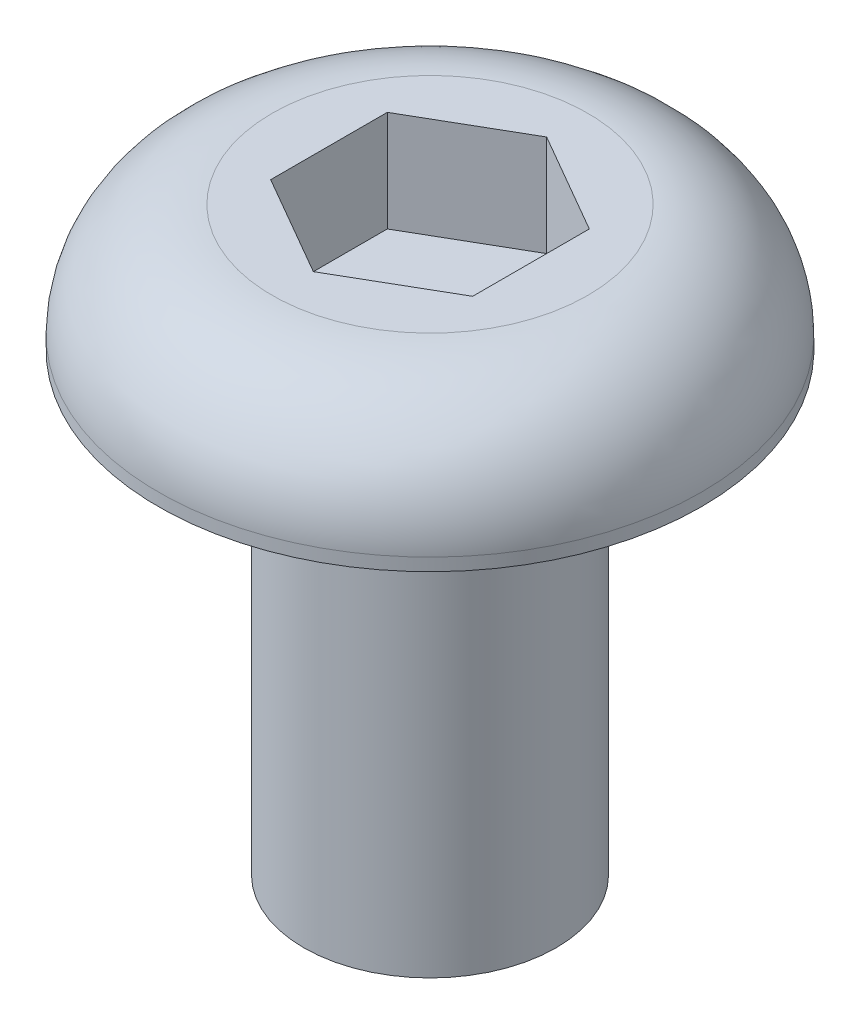
from build123d import *

# Parameters (mm, degrees)
CORTE_EXTRUS_O1_DEPTH = 4


with BuildPart() as part:
    # Esboço1 → Revolução1 (revolve)
    with BuildSketch(Plane.XY):
        with BuildLine():
            Line((0, 0), (5, 0))
            Line((5, 0), (5, 18))
            Line((5, 18), (10.75, 18))
            Line((10.75, 18), (10.75, 18.5))
            ThreePointArc((10.75, 18.5), (9.431980515, 21.681980515), (6.25, 23))
            Line((6.25, 23), (0, 23))
            Line((0, 23), (0, 0))
        make_face()
    revolve(axis=Axis((0, 23, 0), (0, -1, 0)))

    # Esboço2 → Corte-extrusão1 (cut)
    with BuildSketch(Plane(origin=(0, 23, 0), x_dir=(1, 0, 0), z_dir=(0, 1, 0))):
        Polygon((0, 4.618802154), (-4, 2.309401077), (-4, -2.309401077), (0, -4.618802154), (4, -2.309401077), (4, 2.309401077), align=None)
    extrude(amount=-CORTE_EXTRUS_O1_DEPTH, mode=Mode.SUBTRACT)


solid = part.part
